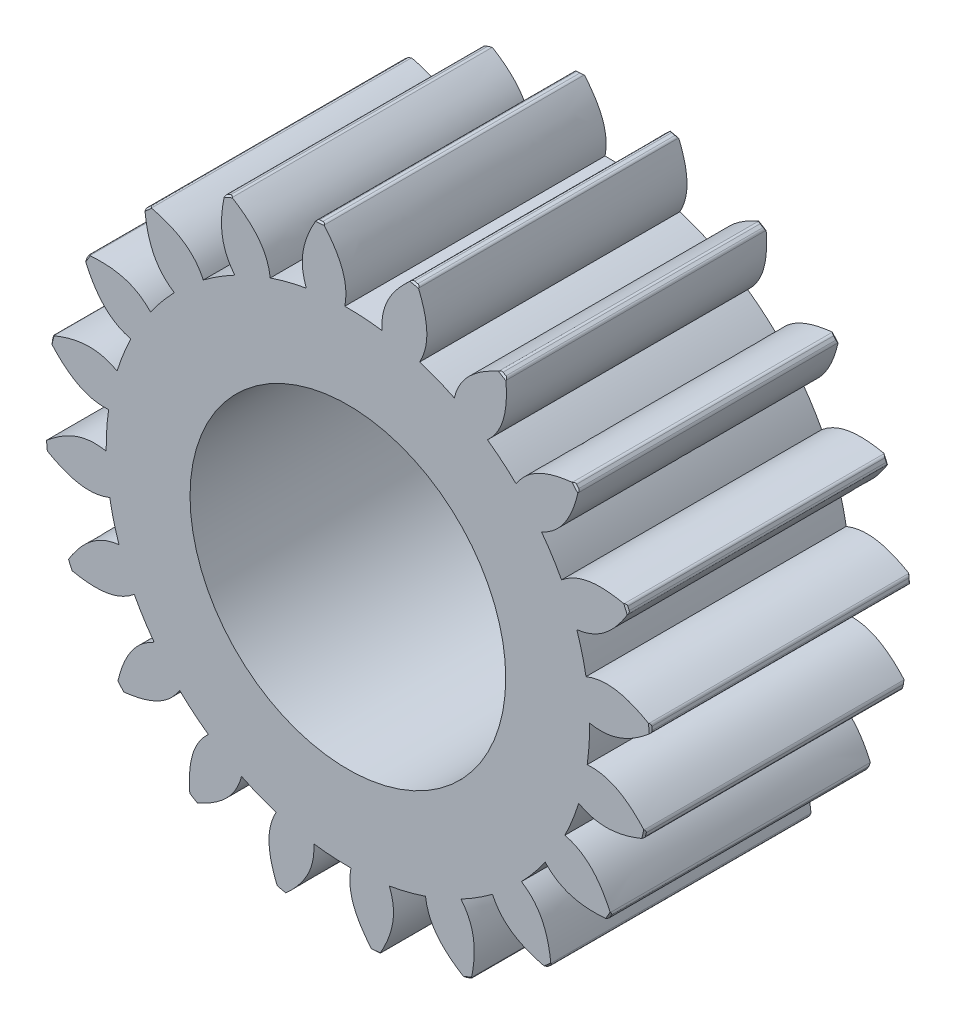
from build123d import *

# Parameters (mm, degrees)
BOSS_EXTRUDE1_DEPTH          = 32.97
CHAMFER1_SIZE                = 0.2
FILLET1_R                    = 0.4
CIRPATTERN1_COUNT            = 20
CHAMFER1_OF_CIRPATTERN1_SIZE = 0.2
FILLET1_OF_CIRPATTERN1_R     = 0.4
SKETCH2_R                    = 20
CUT_EXTRUDE1_DEPTH           = 33.9700001


with BuildPart() as part:
    # Sketch1 → Boss-Extrude1 (new body)
    with BuildSketch(Plane.XY):
        with BuildLine():
            add(Edge.make_bspline(
                [(-0.39142568, 30.622498444), (-0.134544637, 31.928363317), (-0.410006278, 34.76915952), (-2.062590335, 37.117011195), (-3.145698, 38.371272902)],
                knots=[-0.05488558, -0.05488558, -0.05488558, -0.05488558, 0.06321867, 0.225739972, 0.225739972, 0.225739972, 0.225739972], degree=3))
            ThreePointArc((-3.145698, 38.371272902), (-3.565475857, 38.334545542), (-3.984826598, 38.293225993))
            add(Edge.make_bspline(
                [(-3.984826598, 38.293225993), (-4.818040184, 36.860728258), (-6.009278123, 34.2483742), (-5.756105038, 31.40550495), (-5.262798087, 30.169414666)],
                knots=[0, 0, 0, 0, 0.162521302, 0.280625552, 0.280625552, 0.280625552, 0.280625552], degree=3))
            ThreePointArc((-5.262798087, 30.169414666), (2.836173977, -30.493388499), (-0.39142568, 30.622498444))
        make_face()
    boss_extrude1 = extrude(amount=BOSS_EXTRUDE1_DEPTH)

    # Chamfer1
    chamfer1_edges = [part.edges().sort_by_distance(p)[0] for p in [
        (-3.565475857, 38.334545542, 32.97),
        (-3.565475857, 38.334545542, 0),
    ]]
    chamfer(chamfer1_edges, length=CHAMFER1_SIZE)

    # Fillet1
    fillet1_edges = [part.edges().sort_by_distance(p)[0] for p in [
        (-3.984826598, 38.293225993, 16.485),
        (-3.145698, 38.371272902, 16.485),
    ]]
    fillet(fillet1_edges, radius=FILLET1_R)

    # CirPattern1: Boss-Extrude1 ×20 about axis
    cirpattern1_axis = Axis((0, 0, 32.97), (0, 0, 1))
    for i in range(1, CIRPATTERN1_COUNT):
        add(boss_extrude1.rotate(cirpattern1_axis, i * 360 / CIRPATTERN1_COUNT))

    # Chamfer1 of CirPattern1
    chamfer1_of_cirpattern1_edges = [part.edges().sort_by_distance(p)[0] for p in [
        (-15.236995092, 35.356526704, 32.97),
        (-15.236995092, 35.356526704, 0),
        (-25.417011085, 28.917564689, 32.97),
        (-25.417011085, 28.917564689, 0),
        (-33.109032941, 19.647949961, 32.97),
        (-33.109032941, 19.647949961, 0),
        (-37.56011197, 8.455056996, 32.97),
        (-37.56011197, 8.455056996, 0),
        (-38.334545542, -3.565475857, 32.97),
        (-38.334545542, -3.565475857, 0),
        (-35.356526704, -15.236995092, 32.97),
        (-35.356526704, -15.236995092, 0),
        (-28.917564689, -25.417011085, 32.97),
        (-28.917564689, -25.417011085, 0),
        (-19.647949961, -33.109032941, 32.97),
        (-19.647949961, -33.109032941, 0),
        (-8.455056996, -37.56011197, 32.97),
        (-8.455056996, -37.56011197, 0),
        (3.565475857, -38.334545542, 32.97),
        (3.565475857, -38.334545542, 0),
        (15.236995092, -35.356526704, 32.97),
        (15.236995092, -35.356526704, 0),
        (25.417011085, -28.917564689, 32.97),
        (25.417011085, -28.917564689, 0),
        (33.109032941, -19.647949961, 32.97),
        (33.109032941, -19.647949961, 0),
        (37.56011197, -8.455056996, 32.97),
        (37.56011197, -8.455056996, 0),
        (38.334545542, 3.565475857, 32.97),
        (38.334545542, 3.565475857, 0),
        (35.356526704, 15.236995092, 32.97),
        (35.356526704, 15.236995092, 0),
        (28.917564689, 25.417011085, 32.97),
        (28.917564689, 25.417011085, 0),
        (19.647949961, 33.109032941, 32.97),
        (19.647949961, 33.109032941, 0),
        (8.455056996, 37.56011197, 32.97),
        (8.455056996, 37.56011197, 0),
    ]]
    chamfer(chamfer1_of_cirpattern1_edges, length=CHAMFER1_OF_CIRPATTERN1_SIZE)

    # Fillet1 of CirPattern1
    fillet1_of_cirpattern1_edges = [part.edges().sort_by_distance(p)[0] for p in [
        (-15.623052903, 35.187642973, 16.485),
        (-14.849112004, 35.521174991, 16.485),
        (-25.731985939, 28.637648291, 16.485),
        (-25.098991464, 29.194016981, 16.485),
        (-33.322092905, 19.284401064, 16.485),
        (-32.892006766, 20.009145182, 16.485),
        (-37.650401249, 8.043462299, 16.485),
        (-37.465323273, 8.865638841, 16.485),
        (-38.293225993, -3.984826598, 16.485),
        (-38.371272902, -3.145698, 16.485),
        (-35.187642973, -15.623052903, 16.485),
        (-35.521174991, -14.849112004, 16.485),
        (-28.637648291, -25.731985939, 16.485),
        (-29.194016981, -25.098991464, 16.485),
        (-19.284401064, -33.322092905, 16.485),
        (-20.009145182, -32.892006766, 16.485),
        (-8.043462299, -37.650401249, 16.485),
        (-8.865638841, -37.465323273, 16.485),
        (3.984826598, -38.293225993, 16.485),
        (3.145698, -38.371272902, 16.485),
        (15.623052903, -35.187642973, 16.485),
        (14.849112004, -35.521174991, 16.485),
        (25.731985939, -28.637648291, 16.485),
        (25.098991464, -29.194016981, 16.485),
        (33.322092905, -19.284401064, 16.485),
        (32.892006766, -20.009145182, 16.485),
        (37.650401249, -8.043462299, 16.485),
        (37.465323273, -8.865638841, 16.485),
        (38.293225993, 3.984826598, 16.485),
        (38.371272902, 3.145698, 16.485),
        (35.187642973, 15.623052903, 16.485),
        (35.521174991, 14.849112004, 16.485),
        (28.637648291, 25.731985939, 16.485),
        (29.194016981, 25.098991464, 16.485),
        (19.284401064, 33.322092905, 16.485),
        (20.009145182, 32.892006766, 16.485),
        (8.043462299, 37.650401249, 16.485),
        (8.865638841, 37.465323273, 16.485),
    ]]
    fillet(fillet1_of_cirpattern1_edges, radius=FILLET1_OF_CIRPATTERN1_R)

    # Sketch2 → Cut-Extrude1 (cut, through all)
    with BuildSketch(Plane.XY.offset(32.97)):
        Circle(SKETCH2_R)
    extrude(amount=-CUT_EXTRUDE1_DEPTH, mode=Mode.SUBTRACT)


solid = part.part
